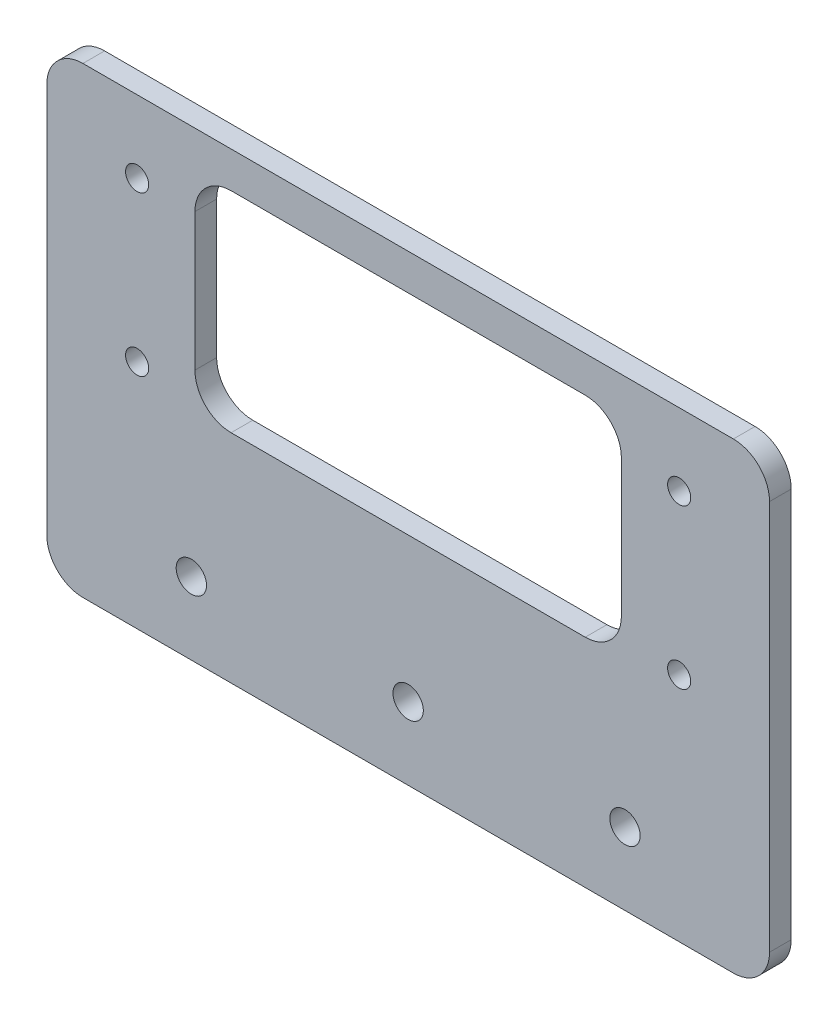
from build123d import *

# Parameters (mm, degrees)
SKETCH_1_W          = 100
SKETCH_1_H          = 64
SKETCH_1_R          = 1.6
SKETCH_1_R_2        = 2.1
EXTRUDE_1_DEPTH     = 3
SKETCH_2_W          = 59
SKETCH_2_H          = 29
CUT_EXTRUDE_1_DEPTH = 10
FILLET_1_R          = 5
FILLET_2_R          = 5


with BuildPart() as part:
    # 草图1 → 凸台-拉伸1 (new body)
    with BuildSketch(Plane.XY):
        Rectangle(SKETCH_1_W, SKETCH_1_H)
        with Locations((-37.5, 0)):
            Circle(SKETCH_1_R, mode=Mode.SUBTRACT)
        with Locations((-37.5, 22)):
            Circle(SKETCH_1_R, mode=Mode.SUBTRACT)
        with Locations((37.5, 0)):
            Circle(SKETCH_1_R, mode=Mode.SUBTRACT)
        with Locations((37.5, 22)):
            Circle(SKETCH_1_R, mode=Mode.SUBTRACT)
        with Locations((-30, -22)):
            Circle(SKETCH_1_R_2, mode=Mode.SUBTRACT)
        with Locations((30, -22)):
            Circle(SKETCH_1_R_2, mode=Mode.SUBTRACT)
        with Locations((0, -22)):
            Circle(SKETCH_1_R_2, mode=Mode.SUBTRACT)
    extrude(amount=EXTRUDE_1_DEPTH)

    # 草图2 → 切除-拉伸1 (cut)
    with BuildSketch(Plane.XY.offset(3)):
        with Locations((0, 12.5)):
            Rectangle(SKETCH_2_W, SKETCH_2_H)
    extrude(amount=-CUT_EXTRUDE_1_DEPTH, mode=Mode.SUBTRACT)

    # 圆角1
    fillet_1_edges = [part.edges().sort_by_distance(p)[0] for p in [
        (29.5, 27, 1.5),
        (29.5, -2, 1.5),
        (-29.5, -2, 1.5),
        (-29.5, 27, 1.5),
    ]]
    fillet(fillet_1_edges, radius=FILLET_1_R)

    # 圆角2
    fillet_2_edges = [part.edges().sort_by_distance(p)[0] for p in [
        (50, -32, 1.5),
        (-50, -32, 1.5),
        (-50, 32, 1.5),
        (50, 32, 1.5),
    ]]
    fillet(fillet_2_edges, radius=FILLET_2_R)


solid = part.part
